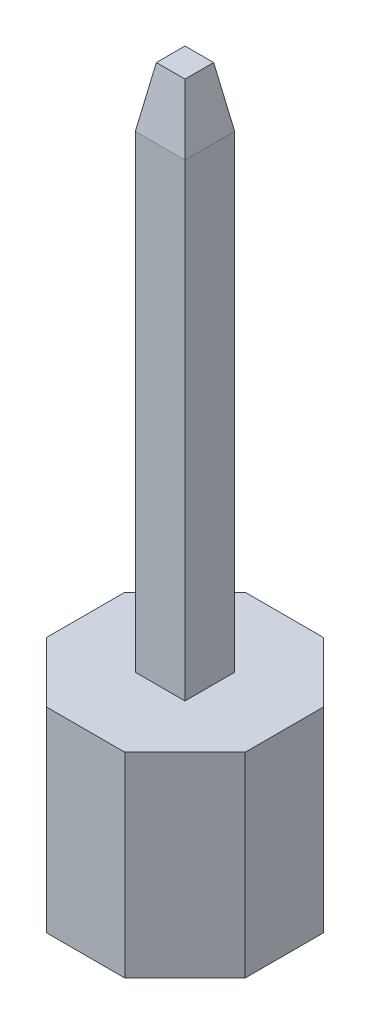
from build123d import *

# Parameters (mm, degrees)
SKETCH1_R             = 0.3175
BOSS_EXTRUDE1_DEPTH   = 1.25
SKETCH2_W             = 0.635
SKETCH2_H             = 0.635
BOSS_EXTRUDE2_DEPTH   = 6.75
CHAMFER2_SIZE         = 0.762
CHAMFER2_SIZE2        = 0.134361159
CHAMFER2_PART_2_SIZE  = 0.762
CHAMFER2_PART_2_SIZE2 = 0.134361159
CHAMFER2_PART_3_SIZE  = 0.762
CHAMFER2_PART_3_SIZE2 = 0.134361159
CHAMFER2_PART_4_SIZE  = 0.762
CHAMFER2_PART_4_SIZE2 = 0.134361159


with BuildPart() as part:
    # Sketch1 → Boss-Extrude1 (new body, symmetric)
    with BuildSketch(Plane(origin=(0, 0, 0), x_dir=(1, 0, 0), z_dir=(0, 1, 0))):
        Polygon((-0.5, 1.27), (-1.27, 0.5), (-1.27, -0.5), (-0.5, -1.27), (0.5, -1.27), (1.27, -0.5), (1.27, 0.5), (0.5, 1.27), align=None)
        with Locations(Location((0, 0, 0), (0, 0, 270))):  # turned: the seam where the file's is
            Circle(SKETCH1_R, mode=Mode.SUBTRACT)
    extrude(amount=BOSS_EXTRUDE1_DEPTH, both=True)


with BuildPart() as body_2:
    # Sketch2 → Boss-Extrude2 (new body)
    with BuildSketch(Plane(origin=(0, 1.25, 0), x_dir=(1, 0, 0), z_dir=(0, 1, 0))):
        Rectangle(SKETCH2_W, SKETCH2_H)
    extrude(amount=BOSS_EXTRUDE2_DEPTH)

    # Chamfer2
    chamfer2_edges = [body_2.edges().sort_by_distance(p)[0] for p in [
        (-0.3175, 8, 0),
    ]]
    chamfer2_side = [body_2.faces().sort_by_distance(p)[0] for p in [
        (-0.3175, 4.625, 0),
    ]]
    chamfer(chamfer2_edges, length=CHAMFER2_SIZE, length2=CHAMFER2_SIZE2, reference=chamfer2_side[0])

    # Chamfer2 part 2
    chamfer2_part_2_edges = [body_2.edges().sort_by_distance(p)[0] for p in [
        (0, 8, 0.3175),
    ]]
    chamfer2_part_2_side = [body_2.faces().sort_by_distance(p)[0] for p in [
        (0, 4.625, 0.3175),
    ]]
    chamfer(chamfer2_part_2_edges, length=CHAMFER2_PART_2_SIZE, length2=CHAMFER2_PART_2_SIZE2, reference=chamfer2_part_2_side[0])

    # Chamfer2 part 3
    chamfer2_part_3_edges = [body_2.edges().sort_by_distance(p)[0] for p in [
        (0.3175, 8, 0),
    ]]
    chamfer2_part_3_side = [body_2.faces().sort_by_distance(p)[0] for p in [
        (0.3175, 4.625, 0),
    ]]
    chamfer(chamfer2_part_3_edges, length=CHAMFER2_PART_3_SIZE, length2=CHAMFER2_PART_3_SIZE2, reference=chamfer2_part_3_side[0])

    # Chamfer2 part 4
    chamfer2_part_4_edges = [body_2.edges().sort_by_distance(p)[0] for p in [
        (0, 8, -0.3175),
    ]]
    chamfer2_part_4_side = [body_2.faces().sort_by_distance(p)[0] for p in [
        (0, 4.625, -0.3175),
    ]]
    chamfer(chamfer2_part_4_edges, length=CHAMFER2_PART_4_SIZE, length2=CHAMFER2_PART_4_SIZE2, reference=chamfer2_part_4_side[0])


solid = Compound([part.part, body_2.part])
